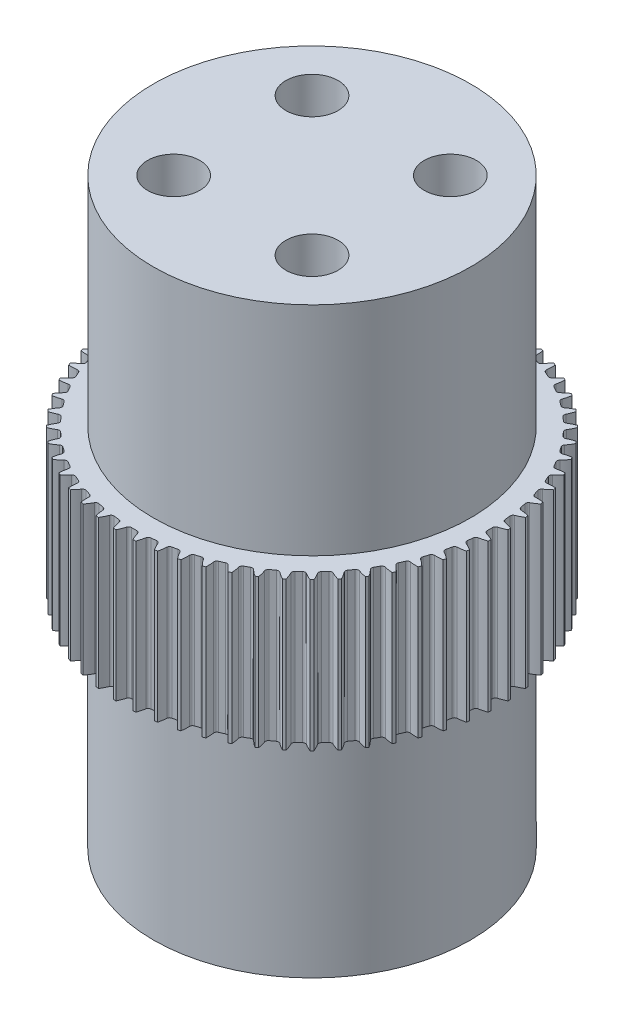
from build123d import *

# Parameters (mm, degrees)
SKETCH1_R           = 19
BOSS_EXTRUDE1_DEPTH = 15
SKETCH2_R           = 8
CUT_EXTRUDE1_DEPTH  = 16
CIRPATTERN1_COUNT   = 60
SKETCH3_R           = 8
BOSS_EXTRUDE2_DEPTH = 15
SKETCH4_R           = 16.05
BOSS_EXTRUDE3_DEPTH = 22
SKETCH5_R           = 16.05
BOSS_EXTRUDE4_DEPTH = 22
CUT_EXTRUDE2_DEPTH  = 125


with BuildPart() as part:
    # Sketch1 → Boss-Extrude1 (new body)
    with BuildSketch(Plane(origin=(0, 0, 0), x_dir=(1, 0, 0), z_dir=(0, 1, 0))):
        Circle(SKETCH1_R)
    extrude(amount=BOSS_EXTRUDE1_DEPTH)

    # Sketch2 → Cut-Extrude1 (cut, through all)
    with BuildSketch(Plane(origin=(0, 15, 0), x_dir=(1, 0, 0), z_dir=(0, 1, 0))):
        Circle(SKETCH2_R)
        with BuildLine():
            Line((-0.268728385, 18), (0.268728385, 18))
            ThreePointArc((0.268728385, 18), (0.449006272, 18.060208667), (0.556922217, 18.216667445))
            ThreePointArc((0.556922217, 18.216667445), (0.746491702, 18.747041733), (1, 19.25))
            ThreePointArc((1, 19.25), (0, 19.401749021), (-1, 19.25))
            ThreePointArc((-1, 19.25), (-0.746491702, 18.747041733), (-0.556922217, 18.216667445))
            ThreePointArc((-0.556922217, 18.216667445), (-0.449006272, 18.060208667), (-0.268728385, 18))
        make_face()
    cut_extrude1 = extrude(amount=-CUT_EXTRUDE1_DEPTH, mode=Mode.SUBTRACT)

    # CirPattern1: Cut-Extrude1 ×60 about axis
    cirpattern1_axis = Axis((0, 0, 0), (0, 1, 0))
    for i in range(1, CIRPATTERN1_COUNT):
        add(cut_extrude1.rotate(cirpattern1_axis, i * 360 / CIRPATTERN1_COUNT), mode=Mode.SUBTRACT)

    # Sketch3 → Boss-Extrude2 (add)
    with BuildSketch(Plane(origin=(0, 15, 0), x_dir=(1, 0, 0), z_dir=(0, 1, 0))):
        Circle(SKETCH3_R)
    extrude(amount=-BOSS_EXTRUDE2_DEPTH)

    # Sketch4 → Boss-Extrude3 (add)
    with BuildSketch(Plane(origin=(0, 15, 0), x_dir=(1, 0, 0), z_dir=(0, 1, 0))):
        Circle(SKETCH4_R)
    extrude(amount=BOSS_EXTRUDE3_DEPTH)

    # Sketch5 → Boss-Extrude4 (add)
    with BuildSketch(Plane.XZ):
        Circle(SKETCH5_R)
    extrude(amount=BOSS_EXTRUDE4_DEPTH)

    # Sketch6 → Cut-Extrude2 (cut)
    with BuildSketch(Plane.XZ.offset(22)):
        with BuildLine():
            ThreePointArc((-4.36, 7), (-8.866761902, 8.866761902), (-7, 4.36))
            Line((-7, 4.36), (-7, 7))
            Line((-7, 7), (-4.36, 7))
        make_face()
        with BuildLine():
            Line((-7, 7), (-7, 4.36))
            ThreePointArc((-7, 4.36), (-5.133238098, 5.133238098), (-4.36, 7))
            Line((-4.36, 7), (-7, 7))
        make_face()
        with BuildLine():
            ThreePointArc((4.36, 7), (5.133238098, 5.133238098), (7, 4.36))
            Line((7, 4.36), (7, 7))
            Line((7, 7), (4.36, 7))
        make_face()
        with BuildLine():
            Line((7, 7), (7, 4.36))
            ThreePointArc((7, 4.36), (8.866761902, 5.133238098), (9.64, 7))
            ThreePointArc((9.64, 7), (7, 9.64), (4.36, 7))
            Line((4.36, 7), (7, 7))
        make_face()
        with BuildLine():
            ThreePointArc((7, -4.36), (5.133238098, -5.133238098), (4.36, -7))
            Line((4.36, -7), (7, -7))
            Line((7, -7), (7, -4.36))
        make_face()
        with BuildLine():
            Line((7, -7), (4.36, -7))
            ThreePointArc((4.36, -7), (7, -9.64), (9.64, -7))
            ThreePointArc((9.64, -7), (8.866761902, -5.133238098), (7, -4.36))
            Line((7, -4.36), (7, -7))
        make_face()
        with BuildLine():
            Line((-7, -4.36), (-7, -7))
            Line((-7, -7), (-4.36, -7))
            ThreePointArc((-4.36, -7), (-5.133238098, -5.133238098), (-7, -4.36))
        make_face()
        with BuildLine():
            Line((-4.36, -7), (-7, -7))
            Line((-7, -7), (-7, -4.36))
            ThreePointArc((-7, -4.36), (-8.866761902, -8.866761902), (-4.36, -7))
        make_face()
    extrude(amount=-CUT_EXTRUDE2_DEPTH, mode=Mode.SUBTRACT)


solid = part.part
